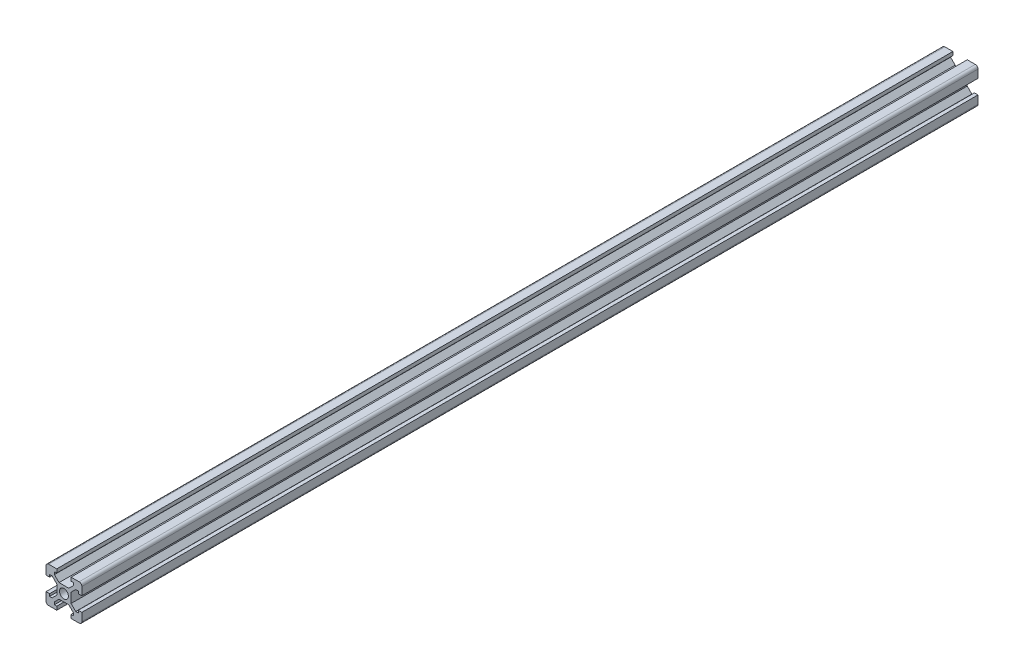
from build123d import *

# Parameters (mm, degrees)
SKETCH_1_R      = 2.5
EXTRUDE_1_DEPTH = 500
FILLET_1_R      = 1.5


with BuildPart() as part:
    # Эскиз1 → Бобышка-Вытянуть1 (new body)
    with BuildSketch(Plane.XY):
        Polygon((14, 20), (20, 20), (20, 14), (18, 14), (18, 15.3), (16.572792206, 15.3), (14, 12.727207794), (14, 7.272792206), (16.572792206, 4.7), (18, 4.7), (18, 6), (20, 6), (20, 0), (14, 0), (14, 2), (15.3, 2), (15.3, 3.427207794), (12.684044775, 6), (7.272792206, 6), (4.7, 3.427207794), (4.7, 2), (6, 2), (6, 0), (0, 0), (0, 6), (2, 6), (2, 4.7), (3.427207794, 4.7), (6, 7.272792206), (6, 12.727207794), (3.427207794, 15.3), (2, 15.3), (2, 14), (0, 14), (0, 20), (6, 20), (6, 18), (4.7, 18), (4.7, 16.572792206), (7.272792206, 14), (12.727207794, 14), (15.3, 16.572792206), (15.3, 18), (14, 18), align=None)
        with Locations((10, 10)):
            Circle(SKETCH_1_R, mode=Mode.SUBTRACT)
    extrude(amount=EXTRUDE_1_DEPTH)

    # Скругление1
    fillet_1_edges = [part.edges().sort_by_distance(p)[0] for p in [
        (0, 20, 250),
        (20, 20, 250),
        (20, 0, 250),
        (0, 0, 250),
    ]]
    fillet(fillet_1_edges, radius=FILLET_1_R)


solid = part.part
